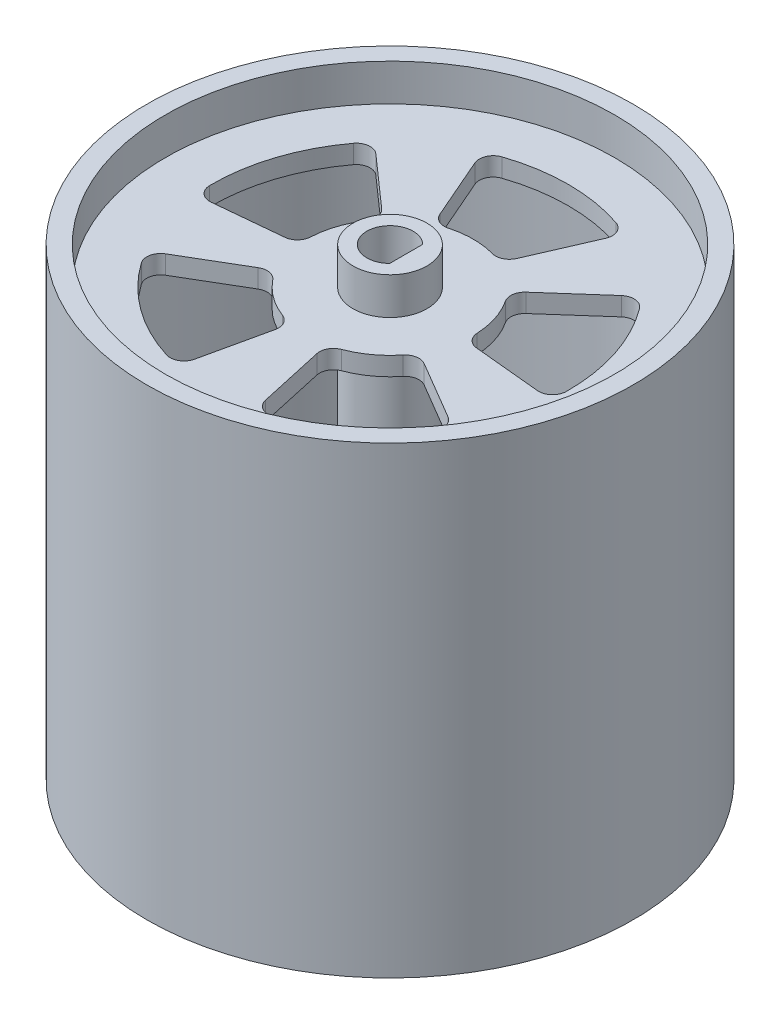
from build123d import *

# Parameters (mm, degrees)
SKETCH1_R           = 52.5
SKETCH1_R_2         = 48.5
BOSS_EXTRUDE1_DEPTH = 100
SKETCH2_R           = 8
BOSS_EXTRUDE2_DEPTH = 100
BOSS_EXTRUDE3_START = -8
SKETCH2_3_R         = 48.5
SKETCH2_3_R_2       = 8
BOSS_EXTRUDE3_DEPTH = 4
BOSS_EXTRUDE4_START = -88
SKETCH2_4_R         = 48.5
SKETCH2_4_R_2       = 8
BOSS_EXTRUDE4_DEPTH = 4


with BuildPart() as part:
    # Sketch1 → Boss-Extrude1 (new body)
    with BuildSketch(Plane(origin=(0, 0, 0), x_dir=(1, 0, 0), z_dir=(0, 1, 0))):
        Circle(SKETCH1_R)
        Circle(SKETCH1_R_2, mode=Mode.SUBTRACT)
    extrude(amount=BOSS_EXTRUDE1_DEPTH)



with BuildPart() as body_2:
    # Sketch2 → Boss-Extrude2 (new body)
    with BuildSketch(Plane.XZ):
        Circle(SKETCH2_R)
        with BuildLine():
            ThreePointArc((3.5, -3.570714214), (-5, 0), (3.5, 3.570714214))
            Line((3.5, 3.570714214), (3.5, -3.570714214))
        make_face(mode=Mode.SUBTRACT)
    extrude(amount=-BOSS_EXTRUDE2_DEPTH)


with BuildPart() as part_1:
    add(part.part)

    add(body_2.part)  # Boss-Extrude3 merges body 2
    # Sketch2_3 → Boss-Extrude3 (add)
    with BuildSketch(Plane.XZ.offset(BOSS_EXTRUDE3_START)):
        Circle(SKETCH2_3_R)
        Circle(SKETCH2_3_R_2, mode=Mode.SUBTRACT)
        with BuildLine():
            Line((4.498612897, 20.291931451), (7.656121129, 34.53453068))
            ThreePointArc((7.656121129, 34.53453068), (9.081556968, 36.48129187), (11.479516965, 36.748750866))
            ThreePointArc((11.479516965, 36.748750866), (22.629732213, 31.147154283), (31.402773148, 22.273657954))
            ThreePointArc((31.402773148, 22.273657954), (31.889414918, 19.910413097), (30.4784189, 17.953160762))
            Line((30.4784189, 17.953160762), (17.908625798, 10.548986777))
            ThreePointArc((17.908625798, 10.548986777), (15.84479345, 10.183097432), (14.045152036, 11.257606507))
            ThreePointArc((14.045152036, 11.257606507), (10.580134541, 14.562305899), (6.366429359, 16.836525093))
            ThreePointArc((6.366429359, 16.836525093), (4.78839072, 18.216044222), (4.498612897, 20.291931451))
        make_face(mode=Mode.SUBTRACT)
        with BuildLine():
            ThreePointArc((-31.402773148, 22.273657954), (-22.629732213, 31.147154283), (-11.479516965, 36.748750866))
            ThreePointArc((-11.479516965, 36.748750866), (-9.081556968, 36.48129187), (-7.656121129, 34.53453068))
            Line((-7.656121129, 34.53453068), (-4.498612897, 20.291931451))
            ThreePointArc((-4.498612897, 20.291931451), (-4.78839072, 18.216044222), (-6.366429359, 16.836525093))
            ThreePointArc((-6.366429359, 16.836525093), (-10.580134541, 14.562305899), (-14.045152036, 11.257606507))
            ThreePointArc((-14.045152036, 11.257606507), (-15.84479345, 10.183097432), (-17.908625798, 10.548986777))
            Line((-17.908625798, 10.548986777), (-30.4784189, 17.953160762))
            ThreePointArc((-30.4784189, 17.953160762), (-31.889414918, 19.910413097), (-31.402773148, 22.273657954))
        make_face(mode=Mode.SUBTRACT)
        with BuildLine():
            Line((8.287843762, -19.060735709), (14.104955724, -32.439177302))
            ThreePointArc((14.104955724, -32.439177302), (14.096031424, -34.851990353), (12.313249487, -36.477854749))
            ThreePointArc((12.313249487, -36.477854749), (0, -38.5), (-12.313249487, -36.477854749))
            ThreePointArc((-12.313249487, -36.477854749), (-14.096031424, -34.851990353), (-14.104955724, -32.439177302))
            Line((-14.104955724, -32.439177302), (-8.287843762, -19.060735709))
            ThreePointArc((-8.287843762, -19.060735709), (-6.83323268, -17.551634794), (-4.745711605, -17.363128214))
            ThreePointArc((-4.745711605, -17.363128214), (0, -18), (4.745711605, -17.363128214))
            ThreePointArc((4.745711605, -17.363128214), (6.83323268, -17.551634794), (8.287843762, -19.060735709))
        make_face(mode=Mode.SUBTRACT)
        with BuildLine():
            Line((-15.566752332, -13.772299075), (-26.492819932, -23.438867123))
            ThreePointArc((-26.492819932, -23.438867123), (-28.790299268, -24.175979847), (-30.887498112, -22.982873197))
            ThreePointArc((-30.887498112, -22.982873197), (-36.615675877, -11.897154283), (-38.497504807, 0.438319126))
            ThreePointArc((-38.497504807, 0.438319126), (-37.502125795, 2.636265233), (-35.21016198, 3.390352984))
            Line((-35.21016198, 3.390352984), (-20.688921471, 1.992116557))
            ThreePointArc((-20.688921471, 1.992116557), (-18.804181667, 1.075037038), (-17.979821767, -0.852061747))
            ThreePointArc((-17.979821767, -0.852061747), (-17.119017293, -5.562305899), (-15.046810695, -9.87894164))
            ThreePointArc((-15.046810695, -9.87894164), (-14.581011618, -11.922543898), (-15.566752332, -13.772299075))
        make_face(mode=Mode.SUBTRACT)
        with BuildLine():
            Line((20.688921471, 1.992116557), (35.21016198, 3.390352984))
            ThreePointArc((35.21016198, 3.390352984), (37.502125795, 2.636265233), (38.497504807, 0.438319126))
            ThreePointArc((38.497504807, 0.438319126), (36.615675877, -11.897154283), (30.887498112, -22.982873197))
            ThreePointArc((30.887498112, -22.982873197), (28.790299268, -24.175979847), (26.492819932, -23.438867123))
            Line((26.492819932, -23.438867123), (15.566752332, -13.772299075))
            ThreePointArc((15.566752332, -13.772299075), (14.581011618, -11.922543898), (15.046810695, -9.87894164))
            ThreePointArc((15.046810695, -9.87894164), (17.119017293, -5.562305899), (17.979821767, -0.852061747))
            ThreePointArc((17.979821767, -0.852061747), (18.804181667, 1.075037038), (20.688921471, 1.992116557))
        make_face(mode=Mode.SUBTRACT)
    extrude(amount=-BOSS_EXTRUDE3_DEPTH)

    # Sketch2_4 → Boss-Extrude4 (add)
    with BuildSketch(Plane.XZ.offset(BOSS_EXTRUDE4_START)):
        Circle(SKETCH2_4_R)
        Circle(SKETCH2_4_R_2, mode=Mode.SUBTRACT)
        with BuildLine():
            Line((4.498612897, 20.291931451), (7.656121129, 34.53453068))
            ThreePointArc((7.656121129, 34.53453068), (9.081556968, 36.48129187), (11.479516965, 36.748750866))
            ThreePointArc((11.479516965, 36.748750866), (22.629732213, 31.147154283), (31.402773148, 22.273657954))
            ThreePointArc((31.402773148, 22.273657954), (31.889414918, 19.910413097), (30.4784189, 17.953160762))
            Line((30.4784189, 17.953160762), (17.908625798, 10.548986777))
            ThreePointArc((17.908625798, 10.548986777), (15.84479345, 10.183097432), (14.045152036, 11.257606507))
            ThreePointArc((14.045152036, 11.257606507), (10.580134541, 14.562305899), (6.366429359, 16.836525093))
            ThreePointArc((6.366429359, 16.836525093), (4.78839072, 18.216044222), (4.498612897, 20.291931451))
        make_face(mode=Mode.SUBTRACT)
        with BuildLine():
            ThreePointArc((-31.402773148, 22.273657954), (-22.629732213, 31.147154283), (-11.479516965, 36.748750866))
            ThreePointArc((-11.479516965, 36.748750866), (-9.081556968, 36.48129187), (-7.656121129, 34.53453068))
            Line((-7.656121129, 34.53453068), (-4.498612897, 20.291931451))
            ThreePointArc((-4.498612897, 20.291931451), (-4.78839072, 18.216044222), (-6.366429359, 16.836525093))
            ThreePointArc((-6.366429359, 16.836525093), (-10.580134541, 14.562305899), (-14.045152036, 11.257606507))
            ThreePointArc((-14.045152036, 11.257606507), (-15.84479345, 10.183097432), (-17.908625798, 10.548986777))
            Line((-17.908625798, 10.548986777), (-30.4784189, 17.953160762))
            ThreePointArc((-30.4784189, 17.953160762), (-31.889414918, 19.910413097), (-31.402773148, 22.273657954))
        make_face(mode=Mode.SUBTRACT)
        with BuildLine():
            Line((8.287843762, -19.060735709), (14.104955724, -32.439177302))
            ThreePointArc((14.104955724, -32.439177302), (14.096031424, -34.851990353), (12.313249487, -36.477854749))
            ThreePointArc((12.313249487, -36.477854749), (0, -38.5), (-12.313249487, -36.477854749))
            ThreePointArc((-12.313249487, -36.477854749), (-14.096031424, -34.851990353), (-14.104955724, -32.439177302))
            Line((-14.104955724, -32.439177302), (-8.287843762, -19.060735709))
            ThreePointArc((-8.287843762, -19.060735709), (-6.83323268, -17.551634794), (-4.745711605, -17.363128214))
            ThreePointArc((-4.745711605, -17.363128214), (0, -18), (4.745711605, -17.363128214))
            ThreePointArc((4.745711605, -17.363128214), (6.83323268, -17.551634794), (8.287843762, -19.060735709))
        make_face(mode=Mode.SUBTRACT)
        with BuildLine():
            Line((-15.566752332, -13.772299075), (-26.492819932, -23.438867123))
            ThreePointArc((-26.492819932, -23.438867123), (-28.790299268, -24.175979847), (-30.887498112, -22.982873197))
            ThreePointArc((-30.887498112, -22.982873197), (-36.615675877, -11.897154283), (-38.497504807, 0.438319126))
            ThreePointArc((-38.497504807, 0.438319126), (-37.502125795, 2.636265233), (-35.21016198, 3.390352984))
            Line((-35.21016198, 3.390352984), (-20.688921471, 1.992116557))
            ThreePointArc((-20.688921471, 1.992116557), (-18.804181667, 1.075037038), (-17.979821767, -0.852061747))
            ThreePointArc((-17.979821767, -0.852061747), (-17.119017293, -5.562305899), (-15.046810695, -9.87894164))
            ThreePointArc((-15.046810695, -9.87894164), (-14.581011618, -11.922543898), (-15.566752332, -13.772299075))
        make_face(mode=Mode.SUBTRACT)
        with BuildLine():
            Line((20.688921471, 1.992116557), (35.21016198, 3.390352984))
            ThreePointArc((35.21016198, 3.390352984), (37.502125795, 2.636265233), (38.497504807, 0.438319126))
            ThreePointArc((38.497504807, 0.438319126), (36.615675877, -11.897154283), (30.887498112, -22.982873197))
            ThreePointArc((30.887498112, -22.982873197), (28.790299268, -24.175979847), (26.492819932, -23.438867123))
            Line((26.492819932, -23.438867123), (15.566752332, -13.772299075))
            ThreePointArc((15.566752332, -13.772299075), (14.581011618, -11.922543898), (15.046810695, -9.87894164))
            ThreePointArc((15.046810695, -9.87894164), (17.119017293, -5.562305899), (17.979821767, -0.852061747))
            ThreePointArc((17.979821767, -0.852061747), (18.804181667, 1.075037038), (20.688921471, 1.992116557))
        make_face(mode=Mode.SUBTRACT)
    extrude(amount=-BOSS_EXTRUDE4_DEPTH)


solid = part_1.part
